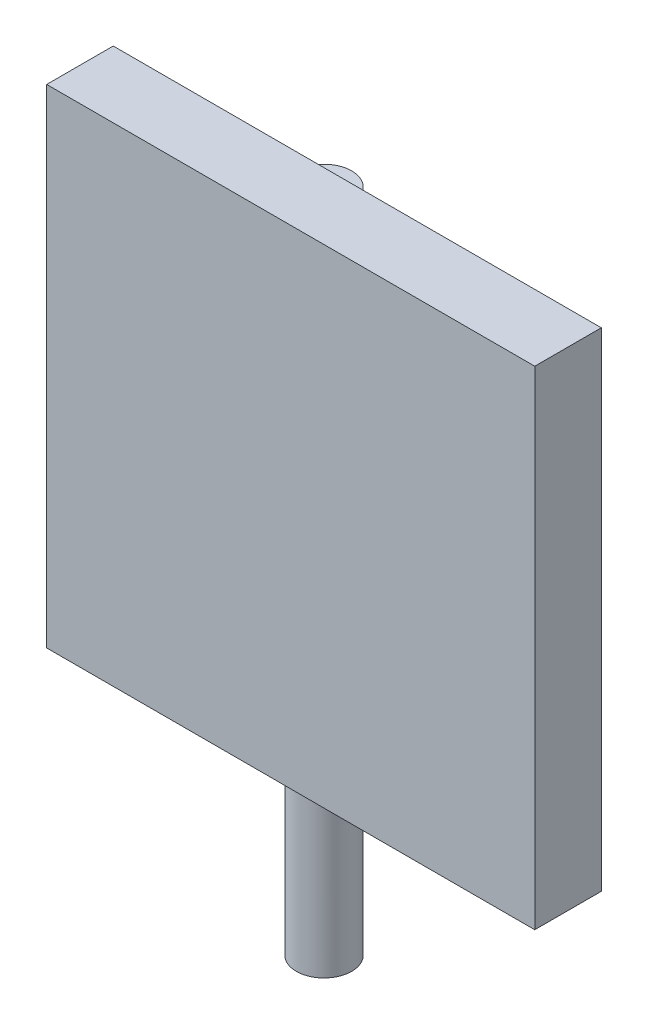
from build123d import *

# Parameters (mm, degrees)
SKETCH1_W                = 4
SKETCH1_H                = 4
BOSS_EXTRUDE1_DEPTH      = 0.1
SKETCH2_R                = 0.25
BOSS_EXTRUDE2_DEPTH      = 4
BOSS_EXTRUDE2_DEPTH_BACK = 2
SKETCH3_R                = 0.25
BOSS_EXTRUDE3_DEPTH      = 0.5
BOSS_EXTRUDE3_TAPER      = 3
SKETCH4_W                = 4.4
SKETCH4_H                = 4.4
BOSS_EXTRUDE4_DEPTH      = 0.3


with BuildPart() as part:
    # Sketch1 → Boss-Extrude1 (new body, symmetric)
    with BuildSketch(Plane.XY):
        with Locations((0, 2)):
            Rectangle(SKETCH1_W, SKETCH1_H)
    extrude(amount=BOSS_EXTRUDE1_DEPTH, both=True)

    # Sketch3 → Boss-Extrude3 (add)
    with BuildSketch(Plane(origin=(0, 0, -0.1), x_dir=(-1, 0, 0), z_dir=(0, 0, -1))):
        with Locations((0.725, 3)):
            Circle(SKETCH3_R)
    extrude(amount=BOSS_EXTRUDE3_DEPTH, taper=BOSS_EXTRUDE3_TAPER)



with BuildPart() as body_2:
    # Sketch2 → Boss-Extrude2 (new body, two sides)
    with BuildSketch(Plane(origin=(0, 0, 0), x_dir=(1, 0, 0), z_dir=(0, 1, 0))) as boss_extrude2_sk:
        with Locations((-0.35, 0.35)):
            Circle(SKETCH2_R)
    extrude(amount=BOSS_EXTRUDE2_DEPTH)
    extrude(boss_extrude2_sk.sketch, amount=-BOSS_EXTRUDE2_DEPTH_BACK)


with BuildPart() as part_1:
    add(part.part)

    add(body_2.part)  # Boss-Extrude4 merges body 2
    # Sketch4 → Boss-Extrude4 (add, symmetric)
    with BuildSketch(Plane.XY):
        with Locations((0, 2)):
            Rectangle(SKETCH4_W, SKETCH4_H)
    extrude(amount=BOSS_EXTRUDE4_DEPTH, both=True)


solid = part_1.part
